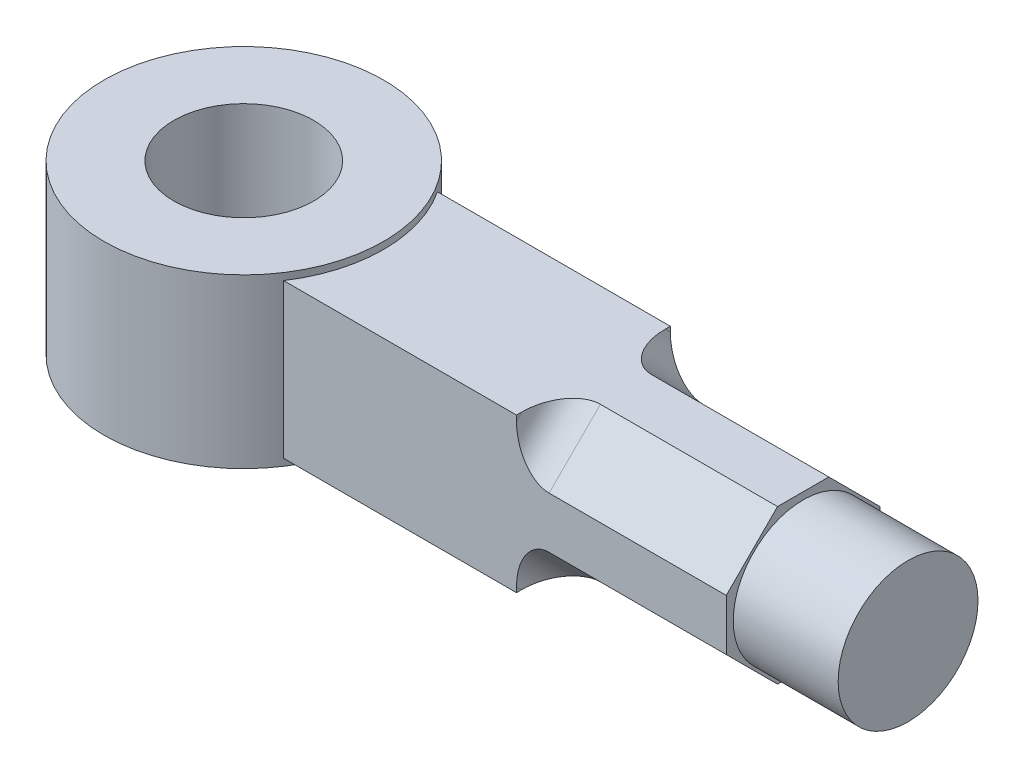
from build123d import *

# Parameters (mm, degrees)
SKETCH1_R           = 30
SKETCH1_R_2         = 15
BOSS_EXTRUDE1_DEPTH = 36
SKETCH2_W           = 94.945060367
SKETCH2_H           = 33
BOSS_EXTRUDE2_DEPTH = 16.5
CUT_EXTRUDE1_DEPTH  = 45
FILLET1_R           = 7
SKETCH4_R           = 15
BOSS_EXTRUDE3_DEPTH = 22.5


with BuildPart() as part:
    # Sketch1 → Boss-Extrude1 (new body)
    with BuildSketch(Plane(origin=(0, 0, 0), x_dir=(1, 0, 0), z_dir=(0, 1, 0))):
        Circle(SKETCH1_R)
        Circle(SKETCH1_R_2, mode=Mode.SUBTRACT)
    extrude(amount=-BOSS_EXTRUDE1_DEPTH)

    # Sketch2 → Boss-Extrude2 (add, symmetric)
    with BuildSketch(Plane(origin=(0, -18, 0), x_dir=(1, 0, 0), z_dir=(0, 1, 0))):
        with Locations((72.527469817, 0)):
            Rectangle(SKETCH2_W, SKETCH2_H)
    extrude(amount=BOSS_EXTRUDE2_DEPTH, both=True)

    # Sketch3 → Cut-Extrude1 (cut)
    with BuildSketch(Plane(origin=(120, 0, 0), x_dir=(0, 0, -1), z_dir=(1, 0, 0))):
        Polygon((5.5, -1.5), (16.5, -12.5), (16.5, -1.5), align=None)
        Polygon((16.5, -34.5), (16.5, -23.5), (5.5, -34.5), align=None)
        Polygon((-16.5, -34.5), (-5.5, -34.5), (-16.5, -23.5), align=None)
        Polygon((-16.5, -1.5), (-16.5, -12.5), (-5.5, -1.5), align=None)
    extrude(amount=-CUT_EXTRUDE1_DEPTH, mode=Mode.SUBTRACT)

    # Fillet1
    fillet1_edges = [part.edges().sort_by_distance(p)[0] for p in [
        (75, -7, 11),
        (75, -29, 11),
        (75, -29, -11),
        (75, -7, -11),
    ]]
    fillet(fillet1_edges, radius=FILLET1_R)

    # Sketch4 → Boss-Extrude3 (add, symmetric)
    with BuildSketch(Plane(origin=(120, 0, 0), x_dir=(0, 0, -1), z_dir=(1, 0, 0))):
        with Locations((0, -18)):
            Circle(SKETCH4_R)
    extrude(amount=BOSS_EXTRUDE3_DEPTH, both=True)


solid = part.part
